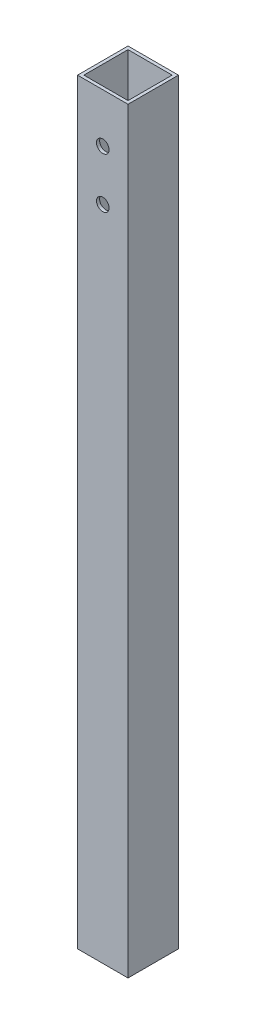
from build123d import *

# Parameters (mm, degrees)
SKETCH1_W           = 25.4
SKETCH1_H           = 25.4
SKETCH1_W_2         = 22.225
SKETCH1_H_2         = 22.225
BOSS_EXTRUDE1_DEPTH = 381
SKETCH2_R           = 3.175
CUT_EXTRUDE1_DEPTH  = 26.4


with BuildPart() as part:
    # Sketch1 → Boss-Extrude1 (new body)
    with BuildSketch(Plane(origin=(0, 0, 0), x_dir=(1, 0, 0), z_dir=(0, 1, 0))):
        Rectangle(SKETCH1_W, SKETCH1_H)
        Rectangle(SKETCH1_W_2, SKETCH1_H_2, mode=Mode.SUBTRACT)
    extrude(amount=BOSS_EXTRUDE1_DEPTH)

    # Sketch2 → Cut-Extrude1 (cut, through all)
    with BuildSketch(Plane.XY.offset(12.7)):
        with Locations((0, 356.362)):
            Circle(SKETCH2_R)
        with Locations((0, 330.962)):
            Circle(SKETCH2_R)
    extrude(amount=-CUT_EXTRUDE1_DEPTH, mode=Mode.SUBTRACT)


solid = part.part
